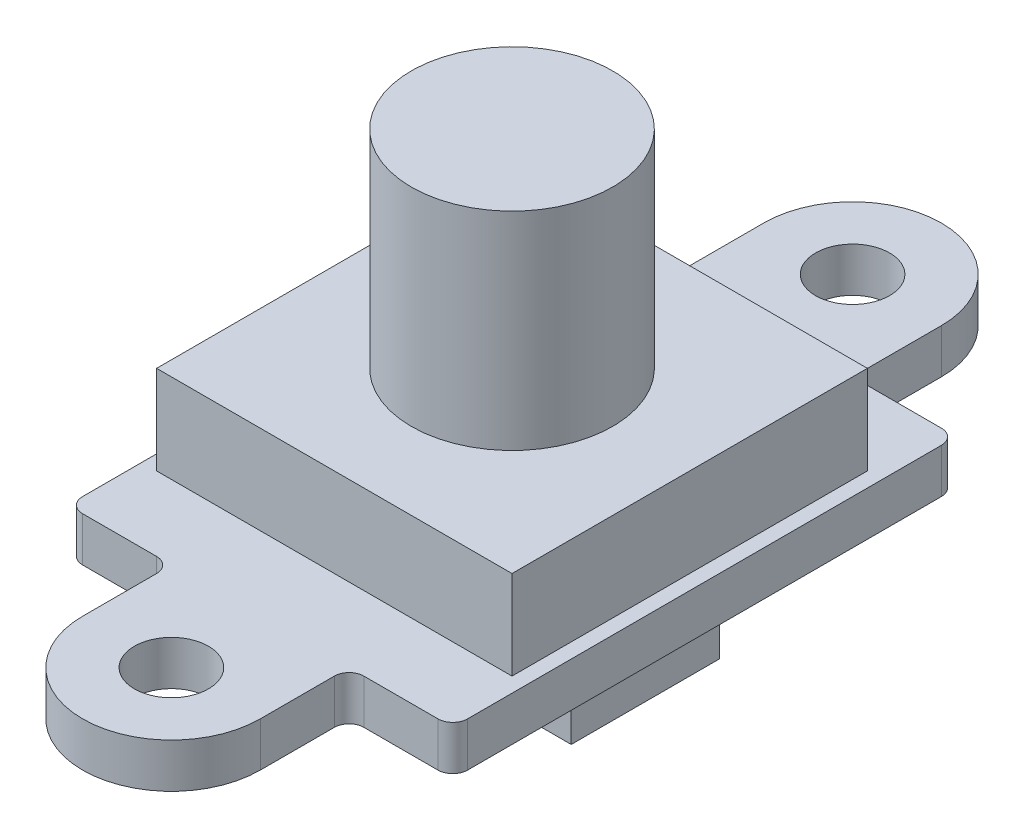
from build123d import *

# Parameters (mm, degrees)
SKETCH_1_R      = 1.25
PCB_DEPTH       = 1.5
SKETCH_6_W      = 5
SKETCH_6_H      = 5
EXTRUDE_2_DEPTH = 3
SKETCH_3_W      = 12
SKETCH_3_H      = 12
BUTTON_DEPTH    = 3
SKETCH_7_R      = 3.4
EXTRUDE_3_DEPTH = 7
FILLET_1_R      = 0.5


with BuildPart() as part:
    # 草图1 → 凸台-拉伸-PCB板 (new body)
    with BuildSketch(Plane(origin=(0, 0, 0), x_dir=(1, 0, 0), z_dir=(0, 1, 0))):
        with BuildLine():
            ThreePointArc((-3, -11.5), (0, -14.5), (3, -11.5))
            Line((3, -11.5), (3, -8.5))
            Line((3, -8.5), (6.5, -8.5))
            Line((6.5, -8.5), (6.5, 8.5))
            Line((6.5, 8.5), (3, 8.5))
            Line((3, 8.5), (3, 11.5))
            ThreePointArc((3, 11.5), (0, 14.5), (-3, 11.5))
            Line((-3, 11.5), (-3, 8.5))
            Line((-3, 8.5), (-6.5, 8.5))
            Line((-6.5, 8.5), (-6.5, -8.5))
            Line((-6.5, -8.5), (-3, -8.5))
            Line((-3, -8.5), (-3, -11.5))
        make_face()
        with Locations((0, -11.5)):
            Circle(SKETCH_1_R, mode=Mode.SUBTRACT)
        with Locations((0, 11.5)):
            Circle(SKETCH_1_R, mode=Mode.SUBTRACT)
    extrude(amount=PCB_DEPTH)

    # 草图6 → 凸台-拉伸2 (add)
    with BuildSketch(Plane.XZ):
        with Locations((2, 0)):
            Rectangle(SKETCH_6_W, SKETCH_6_H)
    extrude(amount=EXTRUDE_2_DEPTH)

    # 草图3 → 凸台-拉伸-Button-底座 (add)
    with BuildSketch(Plane(origin=(0, 1.5, 0), x_dir=(1, 0, 0), z_dir=(0, 1, 0))):
        Rectangle(SKETCH_3_W, SKETCH_3_H)
    extrude(amount=BUTTON_DEPTH)

    # 草图7 → 凸台-拉伸3 (add)
    with BuildSketch(Plane(origin=(0, 4.5, 0), x_dir=(1, 0, 0), z_dir=(0, 1, 0))):
        Circle(SKETCH_7_R)
    extrude(amount=EXTRUDE_3_DEPTH)

    # 圆角1
    fillet_1_edges = [part.edges().sort_by_distance(p)[0] for p in [
        (-6.5, 0.75, -8.5),
        (-3, 0.75, 8.5),
        (-6.5, 0.75, 8.5),
        (3, 0.75, 8.5),
        (6.5, 0.75, -8.5),
        (6.5, 0.75, 8.5),
        (-3, 0.75, -8.5),
        (3, 0.75, -8.5),
    ]]
    fillet(fillet_1_edges, radius=FILLET_1_R)


solid = part.part
